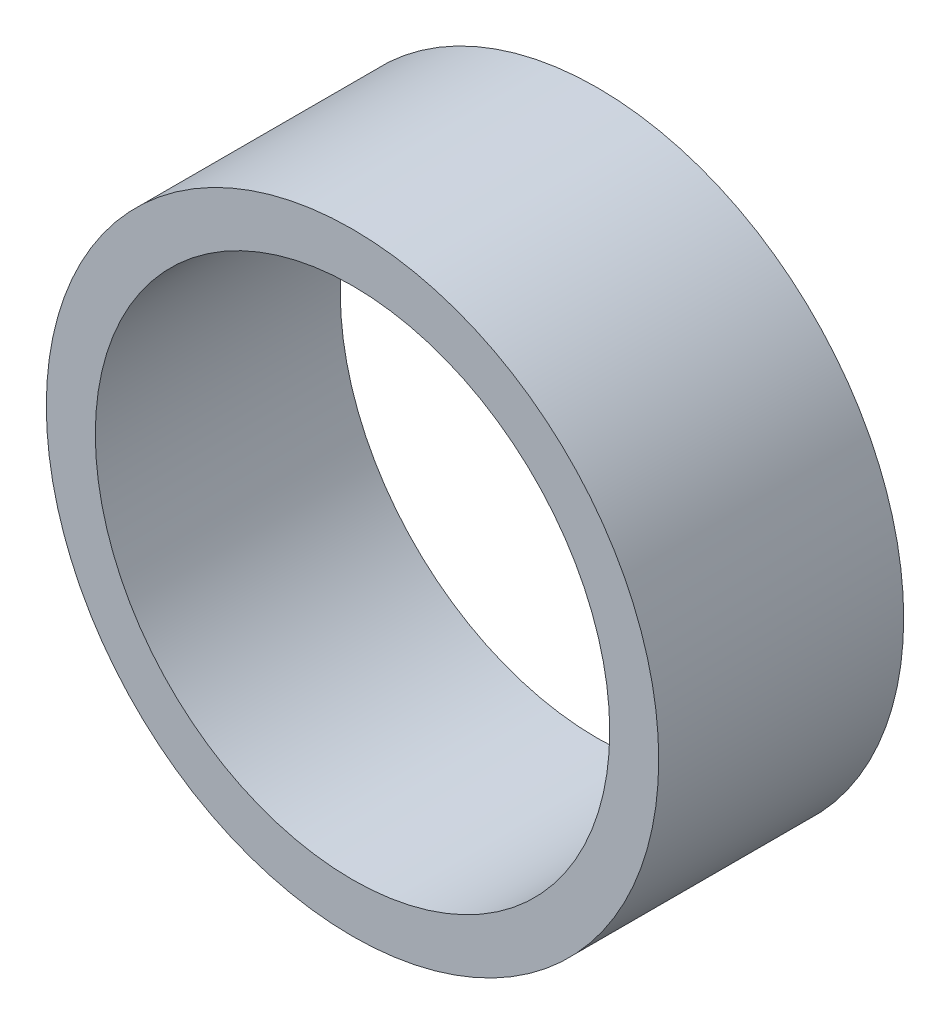
from build123d import *

# Parameters (mm, degrees)
SKETCH1_R           = 5
BOSS_EXTRUDE1_DEPTH = 4
SKETCH3_R           = 4.2
CUT_EXTRUDE1_DEPTH  = 5


with BuildPart() as part:
    # Sketch1 → Boss-Extrude1 (new body)
    with BuildSketch(Plane.XY):
        with Locations((0, 8.25)):
            Circle(SKETCH1_R)
    extrude(amount=-BOSS_EXTRUDE1_DEPTH)

    # Sketch3 → Cut-Extrude1 (cut, through all)
    with BuildSketch(Plane.XY):
        with Locations((0, 8.25)):
            Circle(SKETCH3_R)
    extrude(amount=-CUT_EXTRUDE1_DEPTH, mode=Mode.SUBTRACT)


solid = part.part
